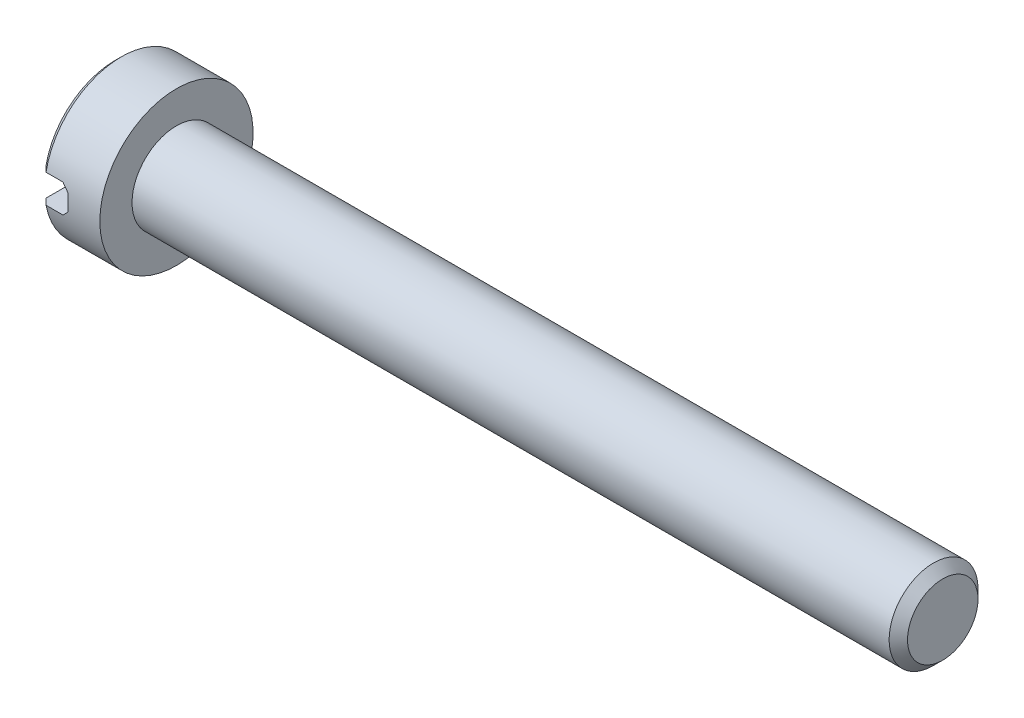
from build123d import *

# Parameters (mm, degrees)
ENL_V_MAT_EXTRU_1_DEPTH = 5
ESQUISSE3_R             = 1.45
EXTRUSION1_DEPTH        = 25
CHANFREIN1_SIZE         = 0.3


with BuildPart() as part:
    # Esquisse1 → Révolution1 (revolve)
    with BuildSketch(Plane.XY, mode=Mode.PRIVATE) as r_volution1_sk:
        Polygon((0, 0), (0, 2.3), (0.2, 2.5), (2, 2.5), (2, 0), align=None)
    revolve(r_volution1_sk.sketch.rotate(Axis((0, 0, 0), (1, 0, 0)), 90), axis=Axis((0, 0, 0), (1, 0, 0)))  # turned: the seam where the file's is

    # Esquisse2 → Enlèv. mat.-Extru.1 (cut, symmetric)
    with BuildSketch(Plane.XY):
        Polygon((0, 0.465549348), (0.753445065, 0.465549348), (0.953445065, 0.265549348), (0.953445065, -0.265549348), (0.753445065, -0.465549348), (0, -0.465549348), align=None)
    extrude(amount=ENL_V_MAT_EXTRU_1_DEPTH, both=True, mode=Mode.SUBTRACT)

    # Esquisse3 → Extrusion1 (add)
    with BuildSketch(Plane(origin=(2, 0, 0), x_dir=(0, 0, -1), z_dir=(1, 0, 0))):
        with Locations(Location((0, 0, 0), (0, 0, 180))):  # turned: the seam where the file's is
            Circle(ESQUISSE3_R)
    extrude(amount=EXTRUSION1_DEPTH)

    # Chanfrein1
    chanfrein1_edges = [part.edges().sort_by_distance(p)[0] for p in [
        (27, 0, -1.45),
    ]]
    chamfer(chanfrein1_edges, length=CHANFREIN1_SIZE)


solid = part.part
